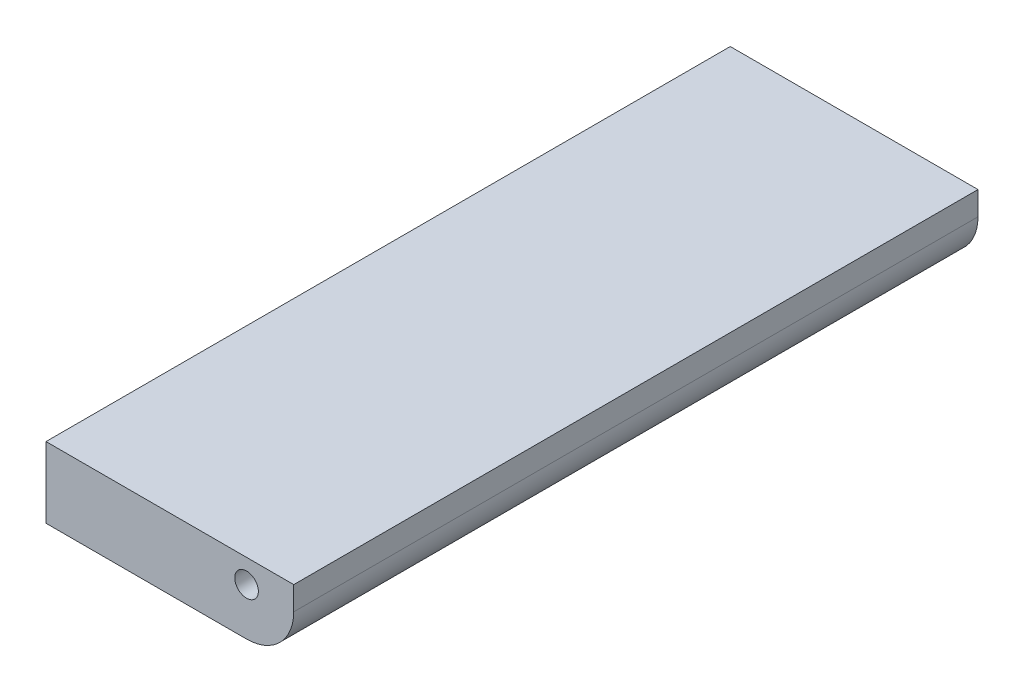
from build123d import *

# Parameters (mm, degrees)
EXTRUDE_1_DEPTH     = 290
SKETCH_2_R          = 5
CUT_EXTRUDE_1_DEPTH = 291


with BuildPart() as part:
    # 草图1 → 凸台-拉伸1 (new body)
    with BuildSketch(Plane.XY):
        with BuildLine():
            Line((0, 0), (-105, 0))
            Line((-105, 0), (-105, -30))
            Line((-105, -30), (-20, -30))
            ThreePointArc((-20, -30), (-5.857864376, -24.142135624), (0, -10))
            Line((0, -10), (0, 0))
        make_face()
    extrude(amount=EXTRUDE_1_DEPTH)

    # 草图2 → 切除-拉伸1 (cut, through all)
    with BuildSketch(Plane.XY.offset(290)):
        with Locations((-20, -10)):
            Circle(SKETCH_2_R)
    extrude(amount=-CUT_EXTRUDE_1_DEPTH, mode=Mode.SUBTRACT)


solid = part.part
